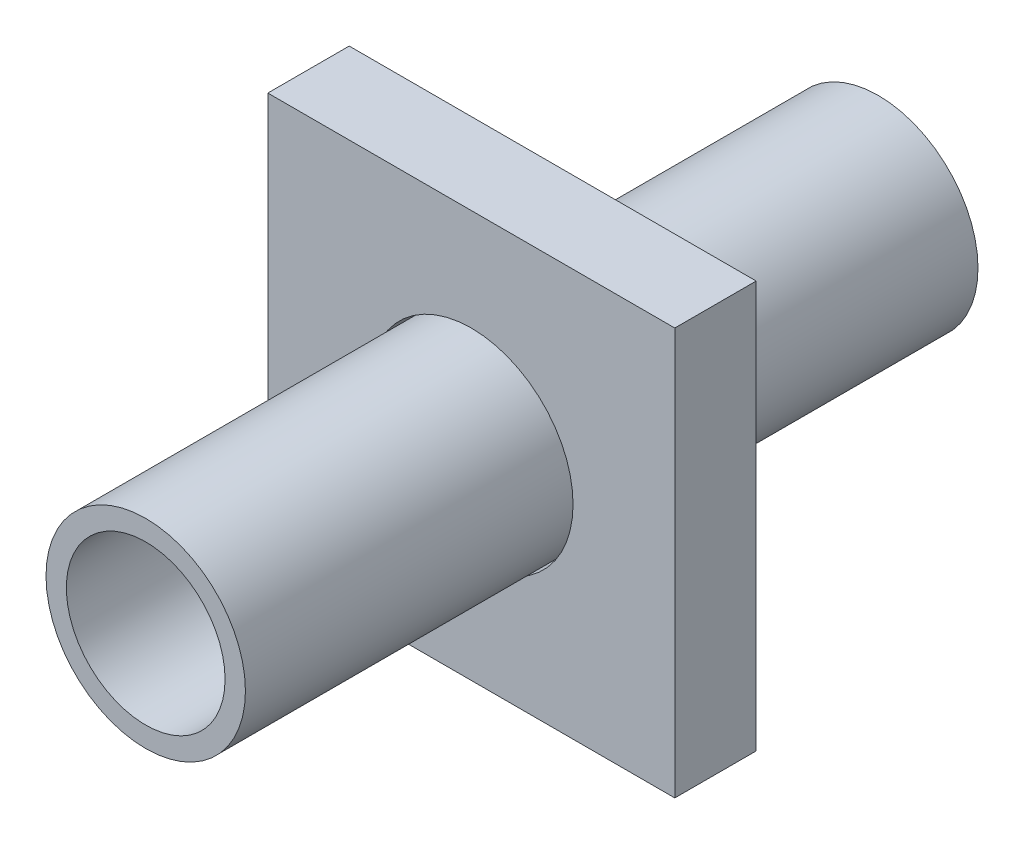
from build123d import *

# Parameters (mm, degrees)
SKETCH1_W                = 1000
SKETCH1_H                = 1000
SKETCH1_R                = 250
BOSS_EXTRUDE1_DEPTH      = 200
SKETCH2_R                = 245
SKETCH2_R_2              = 195
EXTRUDE_THIN1_DEPTH      = 1000
EXTRUDE_THIN1_DEPTH_BACK = 800


with BuildPart() as part:
    # Sketch1 → Boss-Extrude1 (new body)
    with BuildSketch(Plane.XY):
        Rectangle(SKETCH1_W, SKETCH1_H)
        Circle(SKETCH1_R, mode=Mode.SUBTRACT)
    extrude(amount=BOSS_EXTRUDE1_DEPTH)


with BuildPart() as body_2:
    # Sketch2 → Extrude-Thin1 (new body, two sides)
    with BuildSketch(Plane.XY) as extrude_thin1_sk:
        Circle(SKETCH2_R)
        Circle(SKETCH2_R_2, mode=Mode.SUBTRACT)
    extrude(amount=EXTRUDE_THIN1_DEPTH)
    extrude(extrude_thin1_sk.sketch, amount=-EXTRUDE_THIN1_DEPTH_BACK)


solid = Compound([part.part, body_2.part])
